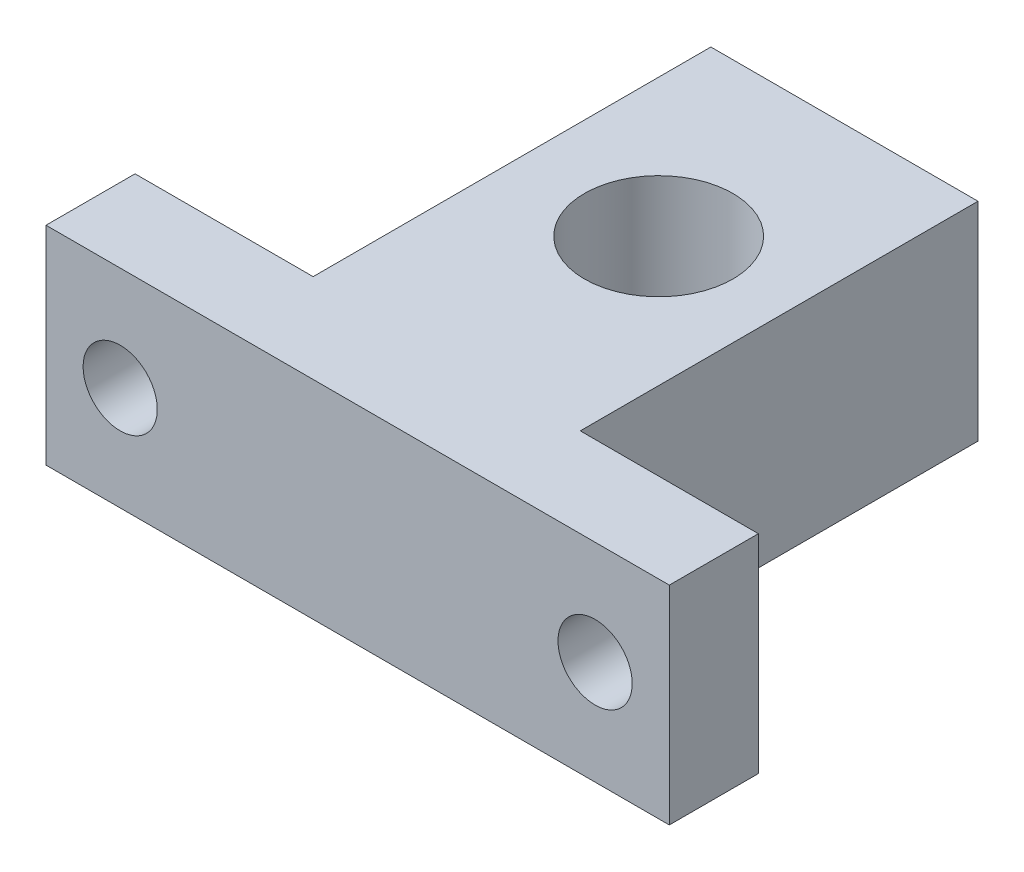
from build123d import *

# Parameters (mm, degrees)
SKETCH_1_R          = 5
EXTRUDE_1_DEPTH     = 14
SKETCH_2_R          = 2.5
CUT_EXTRUDE_1_DEPTH = 14


with BuildPart() as part:
    # 草图1 → 凸台-拉伸1 (new body)
    with BuildSketch(Plane(origin=(0, 0, 0), x_dir=(1, 0, 0), z_dir=(0, 1, 0))):
        Polygon((-9.284210526, 14.447368421), (8.715789474, 14.447368421), (8.715789474, -12.352631579), (20.715789474, -12.352631579), (20.715789474, -18.352631579), (-0.284210526, -18.352631579), (-21.284210526, -18.352631579), (-21.284210526, -12.352631579), (-9.284210526, -12.352631579), align=None)
        with Locations((0, 1.647368421)):
            Circle(SKETCH_1_R, mode=Mode.SUBTRACT)
    extrude(amount=EXTRUDE_1_DEPTH)

    # 草图2 → 切除-拉伸1 (cut)
    with BuildSketch(Plane(origin=(0, 0, 12.352631579), x_dir=(-1, 0, 0), z_dir=(0, 0, -1))):
        with Locations((-15.715789474, 7)):
            Circle(SKETCH_2_R)
        with Locations((16.284210526, 7)):
            Circle(SKETCH_2_R)
    extrude(amount=-CUT_EXTRUDE_1_DEPTH, mode=Mode.SUBTRACT)


solid = part.part
